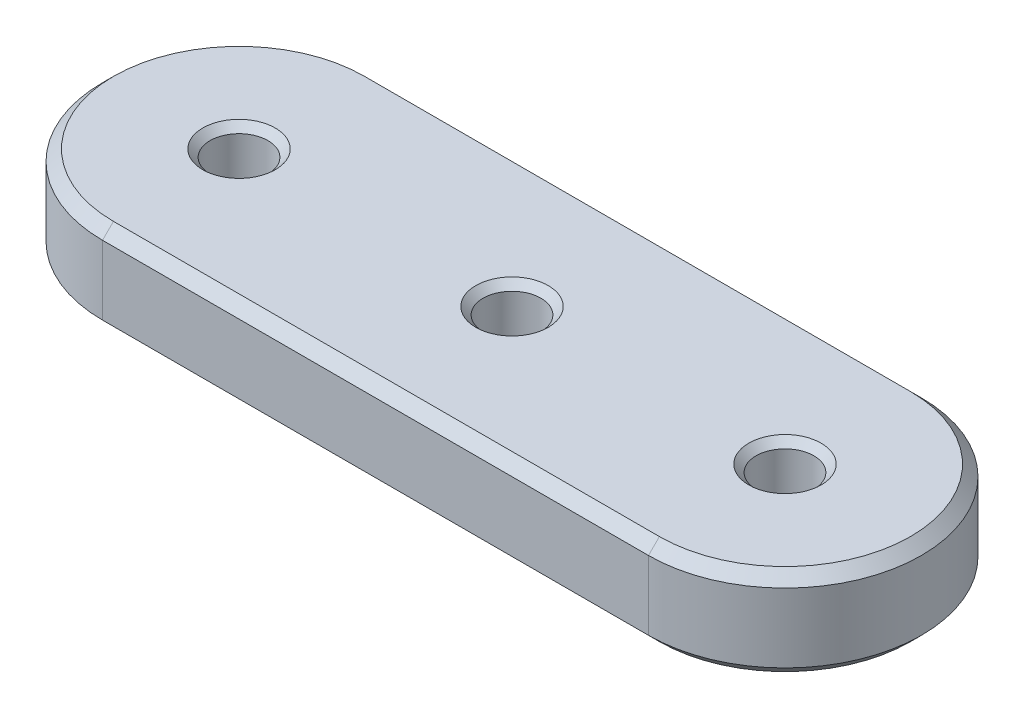
from build123d import *

# Parameters (mm, degrees)
BOSS_EXTRUDE2_DEPTH        = 3.175
F_10_32_TAPPED_HOLE2_D     = 4.0386
F_10_32_TAPPED_HOLE2_DEPTH = 6.35
CHAMFER4_SIZE              = 0.762
CHAMFER5_SIZE              = 0.508


with BuildPart() as part:
    # Sketch10 → Boss-Extrude2 (new body, symmetric)
    with BuildSketch(Plane(origin=(0, 0, 0), x_dir=(1, 0, 0), z_dir=(0, 1, 0))):
        with BuildLine():
            Line((-19.05, 9.525), (19.05, 9.525))
            ThreePointArc((19.05, 9.525), (28.575, 0), (19.05, -9.525))
            Line((19.05, -9.525), (-19.05, -9.525))
            ThreePointArc((-19.05, -9.525), (-28.575, 0), (-19.05, 9.525))
        make_face()
    extrude(amount=BOSS_EXTRUDE2_DEPTH, both=True)

    # #10-32 Tapped Hole2
    with Locations(Plane(origin=(0, 3.175, 0), x_dir=(1, 0, 0), z_dir=(0, 1, 0))):
        with Locations((19.05, 0), (-19.05, 0), (0, 0)):
            Hole(F_10_32_TAPPED_HOLE2_D / 2, depth=F_10_32_TAPPED_HOLE2_DEPTH)

    # Chamfer4
    chamfer4_edges = [part.edges().sort_by_distance(p)[0] for p in [
        (28.575, 3.175, 0),
        (0, 3.175, -9.525),
        (-28.575, 3.175, 0),
        (0, -3.175, -9.525),
        (28.575, -3.175, 0),
        (0, -3.175, 9.525),
        (-28.575, -3.175, 0),
        (0, 3.175, 9.525),
    ]]
    chamfer(chamfer4_edges, length=CHAMFER4_SIZE)

    # Chamfer5
    chamfer5_edges = [part.edges().sort_by_distance(p)[0] for p in [
        (2.0193, 3.175, 0),
        (2.0193, -3.175, 0),
        (-17.0307, 3.175, 0),
        (-17.0307, -3.175, 0),
        (21.0693, 3.175, 0),
        (21.0693, -3.175, 0),
    ]]
    chamfer(chamfer5_edges, length=CHAMFER5_SIZE)


solid = part.part
